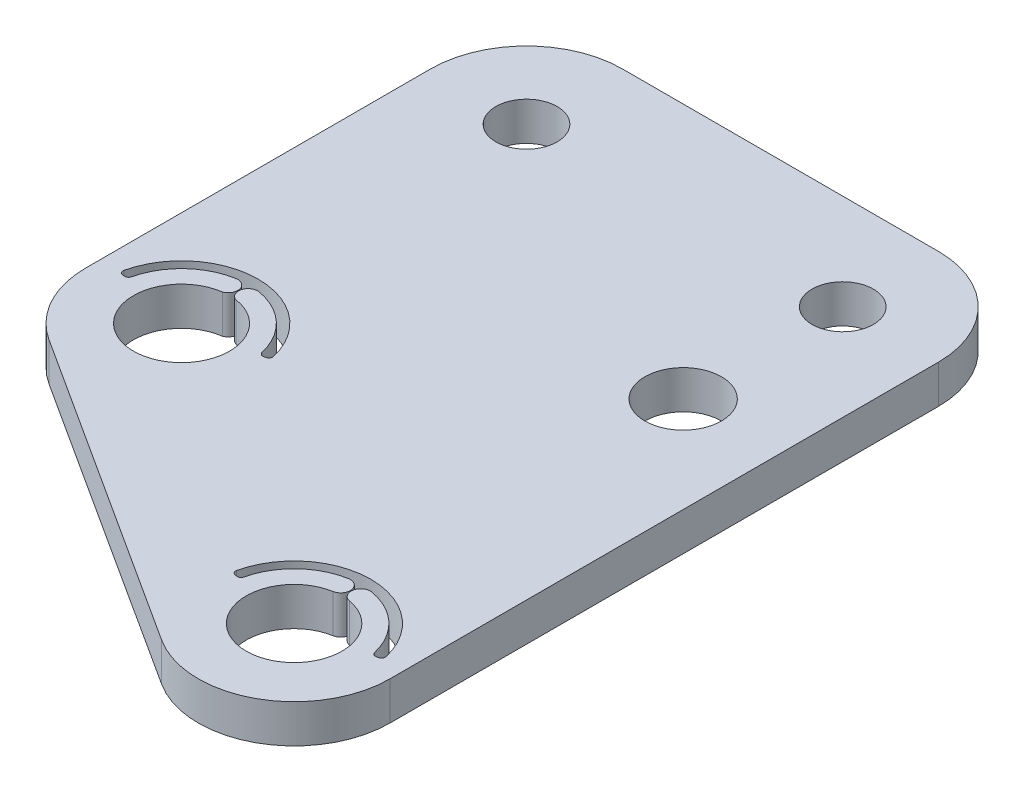
from build123d import *

# Parameters (mm, degrees)
SKETCH1_R           = 2.51
SKETCH1_R_2         = 2.5
SKETCH1_R_3         = 1.6
SKETCH1_R_4         = 2
BOSS_EXTRUDE1_DEPTH = 2
FILLET1_R           = 5
CUT_EXTRUDE2_DEPTH  = 3
SKETCH3_W           = 0.508814103
SKETCH3_H           = 0.135683761
CUT_EXTRUDE3_DEPTH  = 0.4


with BuildPart() as part:
    # Sketch1 → Boss-Extrude1 (new body)
    with BuildSketch(Plane(origin=(0, 0, 0), x_dir=(1, 0, 0), z_dir=(0, 1, 0))):
        Polygon((0, 0), (26.5, 0), (26.5, -42.791666667), (0, -25.727272727), align=None)
        with Locations((5, -23)):
            Circle(SKETCH1_R, mode=Mode.SUBTRACT)
        with Locations((21.5, -33.625)):
            Circle(SKETCH1_R_2, mode=Mode.SUBTRACT)
        with Locations((21.5, -5)):
            Circle(SKETCH1_R_3, mode=Mode.SUBTRACT)
        with Locations((5, -5)):
            Circle(SKETCH1_R_3, mode=Mode.SUBTRACT)
        with Locations((21.5, -13.325)):
            Circle(SKETCH1_R_4, mode=Mode.SUBTRACT)
    extrude(amount=BOSS_EXTRUDE1_DEPTH)

    # Fillet1
    fillet1_edges = [part.edges().sort_by_distance(p)[0] for p in [
        (0, 1, 0),
        (26.5, 1, 0),
        (26.5, 1, 42.791666667),
        (0, 1, 25.727272727),
    ]]
    fillet(fillet1_edges, radius=FILLET1_R)

    # Sketch2 → Cut-Extrude2 (cut, through all)
    with BuildSketch(Plane(origin=(0, 2, 0), x_dir=(1, 0, 0), z_dir=(0, 1, 0))):
        with BuildLine():
            Line((17.861538493, -32.983441068), (17.762917332, -32.966051496))
            ThreePointArc((17.762917332, -32.966051496), (17.630853466, -32.879452656), (17.602786281, -32.724042048))
            ThreePointArc((17.602786281, -32.724042048), (21.5, -29.625), (25.397213719, -32.724042048))
            ThreePointArc((25.397213719, -32.724042048), (25.369146534, -32.879452656), (25.237082668, -32.966051496))
            Line((25.237082668, -32.966051496), (25.138461507, -32.983441068))
            ThreePointArc((25.138461507, -32.983441068), (24.993487988, -32.953351583), (24.908935554, -32.831804949))
            ThreePointArc((24.908935554, -32.831804949), (23.907056069, -31.084118051), (22.107768622, -30.178172864))
            ThreePointArc((22.107768622, -30.178172864), (21.528540656, -30.583752652), (21.934120444, -31.162980617))
            ThreePointArc((21.934120444, -31.162980617), (21.5, -31.125), (21.065879556, -31.162980617))
            ThreePointArc((21.065879556, -31.162980617), (21.471459344, -30.583752652), (20.892231378, -30.178172864))
            ThreePointArc((20.892231378, -30.178172864), (19.092943931, -31.084118051), (18.091064446, -32.831804949))
            ThreePointArc((18.091064446, -32.831804949), (18.006512012, -32.953351583), (17.861538493, -32.983441068))
        make_face()
        with BuildLine():
            Line((1.361538493, -22.358441068), (1.262917332, -22.341051496))
            ThreePointArc((1.262917332, -22.341051496), (1.130853466, -22.254452656), (1.102786281, -22.099042048))
            ThreePointArc((1.102786281, -22.099042048), (5, -19), (8.897213719, -22.099042048))
            ThreePointArc((8.897213719, -22.099042048), (8.869146534, -22.254452656), (8.737082668, -22.341051496))
            Line((8.737082668, -22.341051496), (8.638461507, -22.358441068))
            ThreePointArc((8.638461507, -22.358441068), (8.493487988, -22.328351583), (8.408935554, -22.206804949))
            ThreePointArc((8.408935554, -22.206804949), (7.407056069, -20.459118051), (5.607768622, -19.553172864))
            ThreePointArc((5.607768622, -19.553172864), (5.028540656, -19.958752652), (5.434120444, -20.537980617))
            ThreePointArc((5.434120444, -20.537980617), (5, -20.5), (4.565879556, -20.537980617))
            ThreePointArc((4.565879556, -20.537980617), (4.971459344, -19.958752652), (4.392231378, -19.553172864))
            ThreePointArc((4.392231378, -19.553172864), (2.592943931, -20.459118051), (1.591064446, -22.206804949))
            ThreePointArc((1.591064446, -22.206804949), (1.506512012, -22.328351583), (1.361538493, -22.358441068))
        make_face()
    extrude(amount=-CUT_EXTRUDE2_DEPTH, mode=Mode.SUBTRACT)

    # Sketch3 → Cut-Extrude3 (cut)
    with BuildSketch(Plane(origin=(0, 0, 0), x_dir=(-1, 0, 0), z_dir=(0, 0, -1))):
        Polygon((-16.413127671, 0.4), (-16.238487831, 1.722916667), (-16.22152736, 1.722916667), (-15.675347222, 0.637446581), (-15.130492121, 1.722916667), (-15.113266643, 1.722916667), (-14.937566774, 0.4), (-15.056820079, 0.4), (-15.18349359, 1.351906384), (-15.661036826, 0.4), (-15.687802567, 0.4), (-16.167200855, 1.354026442), (-16.293609358, 0.4), align=None)
        with BuildLine():
            Line((-14.666199252, 1.722916667), (-14.401456914, 1.722916667))
            add(Edge.make_bspline(
                [(-14.401456914, 1.722916667), (-14.383789881, 1.722857859), (-14.349867219, 1.722744941), (-14.301269584, 1.722115323), (-14.257111723, 1.72031073), (-14.217416724, 1.718757783), (-14.182185316, 1.715926008), (-14.151309465, 1.713219454), (-14.124931377, 1.709676433), (-14.108963451, 1.70638599), (-14.101733607, 1.704896167)],
                knots=[0, 0, 0, 0, 5.3002e-05, 0.00010177, 0.00014579, 0.000185584, 0.00022093, 0.000251808, 0.000278568, 0.000300708, 0.000300708, 0.000300708, 0.000300708], degree=3))
            add(Edge.make_bspline(
                [(-14.101733607, 1.704896167), (-14.092054913, 1.702504801), (-14.072903997, 1.697773082), (-14.045330609, 1.687771982), (-14.01905585, 1.676198493), (-13.994188863, 1.662605063), (-13.970854203, 1.646890786), (-13.948811271, 1.629326943), (-13.927960039, 1.610009636), (-13.909143768, 1.588451824), (-13.891401924, 1.565835048), (-13.876438366, 1.541378568), (-13.863539369, 1.515804122), (-13.85326956, 1.488851616), (-13.845000207, 1.460782434), (-13.839169456, 1.431342323), (-13.835672727, 1.400665407), (-13.835316729, 1.379741436), (-13.835136218, 1.369131861)],
                knots=[0, 0, 0, 0, 2.9891e-05, 5.9144e-05, 8.7854e-05, 0.000115962, 0.000144039, 0.000172141, 0.000200452, 0.000229172, 0.000257901, 0.000286582, 0.000315025, 0.000343717, 0.000372985, 0.000402713, 0.000433646, 0.000465465, 0.000465465, 0.000465465, 0.000465465], degree=3))
            add(Edge.make_bspline(
                [(-13.835136218, 1.369131861), (-13.835691464, 1.351504902), (-13.836774894, 1.317110139), (-13.846876346, 1.26719427), (-13.863422829, 1.220631642), (-13.886223596, 1.177480883), (-13.915259528, 1.13858311), (-13.950156101, 1.10441767), (-13.990932782, 1.075827584), (-14.028892672, 1.056001672), (-14.062424527, 1.043304353), (-14.090029381, 1.034370372), (-14.120141601, 1.027467784), (-14.152472677, 1.021284043), (-14.187157154, 1.016615397), (-14.224111901, 1.013196), (-14.263363274, 1.011058904), (-14.290327744, 1.010740646), (-14.304199219, 1.010576923)],
                knots=[0, 0, 0, 0, 5.2832e-05, 0.000103089, 0.000152041, 0.000200646, 0.000248931, 0.000297093, 0.000346506, 0.000397828, 0.000425093, 0.000454008, 0.000484797, 0.000517697, 0.000552739, 0.000589736, 0.000629015, 0.000670628, 0.000670628, 0.000670628, 0.000670628], degree=3))
            Line((-14.304199219, 1.010576923), (-13.818175748, 0.4))
            Line((-13.818175748, 0.4), (-13.964989817, 0.4))
            Line((-13.964989817, 0.4), (-14.451013288, 1.010576923))
            Line((-14.451013288, 1.010576923), (-14.547475962, 1.010576923))
            Line((-14.547475962, 1.010576923), (-14.547475962, 0.4))
            Line((-14.547475962, 0.4), (-14.666199252, 0.4))
            Line((-14.666199252, 0.4), (-14.666199252, 1.722916667))
        make_face()
        with BuildLine():
            Line((-14.547475962, 1.587232906), (-14.547475962, 1.146260684))
            Line((-14.547475962, 1.146260684), (-14.305259248, 1.144405632))
            add(Edge.make_bspline(
                [(-14.305259248, 1.144405632), (-14.293950186, 1.144400629), (-14.272030002, 1.144390932), (-14.240317548, 1.145900484), (-14.210790006, 1.14761775), (-14.183560317, 1.150244437), (-14.158616317, 1.153629619), (-14.135970473, 1.15786408), (-14.11558582, 1.162797449), (-14.09181167, 1.170433183), (-14.065263933, 1.182530696), (-14.036412459, 1.200131346), (-14.011843123, 1.222269078), (-13.991085478, 1.24758345), (-13.974405604, 1.275416199), (-13.962645988, 1.305433695), (-13.955183815, 1.336878139), (-13.95430368, 1.358490102), (-13.953859509, 1.369396868)],
                knots=[0, 0, 0, 0, 3.3922e-05, 6.575e-05, 9.5225e-05, 0.000122649, 0.000147797, 0.000170718, 0.000191735, 0.000210676, 0.000245548, 0.000279004, 0.000311663, 0.000344238, 0.000376915, 0.000408558, 0.000440637, 0.00047332, 0.00047332, 0.00047332, 0.00047332], degree=3))
            add(Edge.make_bspline(
                [(-13.953859509, 1.369396868), (-13.954313882, 1.380035603), (-13.955214283, 1.401117693), (-13.962565455, 1.431981683), (-13.974996858, 1.461111155), (-13.991749609, 1.488387612), (-14.012160004, 1.513147221), (-14.036092629, 1.53433171), (-14.062893105, 1.551812907), (-14.08794204, 1.562983759), (-14.110331162, 1.569832632), (-14.129770349, 1.574652268), (-14.151735104, 1.578524434), (-14.176332078, 1.581626885), (-14.203456265, 1.584293486), (-14.233244815, 1.586089546), (-14.265500086, 1.587153119), (-14.287856218, 1.587205691), (-14.299429087, 1.587232906)],
                knots=[0, 0, 0, 0, 3.189e-05, 6.3195e-05, 9.4547e-05, 0.000126544, 0.000158914, 0.000190451, 0.000222058, 0.000254563, 0.000272332, 0.000292257, 0.000314609, 0.000339196, 0.00036662, 0.000396359, 0.000428707, 0.000463424, 0.000463424, 0.000463424, 0.000463424], degree=3))
            Line((-14.299429087, 1.587232906), (-14.547475962, 1.587232906))
        make_face(mode=Mode.SUBTRACT)
        with BuildLine():
            Line((-13.546808226, 1.722916667), (-13.287366036, 1.722916667))
            add(Edge.make_bspline(
                [(-13.287366036, 1.722916667), (-13.269521437, 1.722897051), (-13.235330394, 1.722859467), (-13.186301191, 1.721719965), (-13.141771918, 1.720197971), (-13.101838589, 1.718088148), (-13.066378338, 1.715594794), (-13.035551621, 1.712097744), (-13.009116134, 1.708446382), (-12.993276493, 1.704734124), (-12.986052684, 1.703041116)],
                knots=[0, 0, 0, 0, 5.3532e-05, 0.00010257, 0.00014712, 0.000187192, 0.000222537, 0.000253734, 0.000280269, 0.000302517, 0.000302517, 0.000302517, 0.000302517], degree=3))
            add(Edge.make_bspline(
                [(-12.986052684, 1.703041116), (-12.976908105, 1.700538176), (-12.958834426, 1.695591276), (-12.932791472, 1.685683113), (-12.908013679, 1.673934795), (-12.884416036, 1.660545389), (-12.862288523, 1.644940428), (-12.841301001, 1.627752484), (-12.821638688, 1.608584718), (-12.80341215, 1.587652117), (-12.78667355, 1.565306085), (-12.772261438, 1.54121304), (-12.760193707, 1.51577853), (-12.749843482, 1.489020245), (-12.742394155, 1.460713486), (-12.736782381, 1.431054937), (-12.733220474, 1.400047777), (-12.732879327, 1.378858482), (-12.732705662, 1.368071832)],
                knots=[0, 0, 0, 0, 2.843e-05, 5.619e-05, 8.3455e-05, 0.000110639, 0.000137472, 0.000164584, 0.000191945, 0.000219742, 0.00024778, 0.000275594, 0.000303805, 0.000332154, 0.000361533, 0.000391471, 0.000422667, 0.000455016, 0.000455016, 0.000455016, 0.000455016], degree=3))
            add(Edge.make_bspline(
                [(-12.732705662, 1.368071832), (-12.732864951, 1.357194517), (-12.73317661, 1.335912317), (-12.73691717, 1.304777364), (-12.741955665, 1.275023687), (-12.749703063, 1.246717258), (-12.759850088, 1.220026178), (-12.771753334, 1.194542557), (-12.786110204, 1.170699943), (-12.802606911, 1.148411777), (-12.820958257, 1.127657137), (-12.8410866, 1.108586426), (-12.862910678, 1.091311275), (-12.886361133, 1.075792954), (-12.911666581, 1.062391325), (-12.938443229, 1.05038782), (-12.966923817, 1.040306794), (-12.986632445, 1.035003765), (-12.996652978, 1.032307525)],
                knots=[0, 0, 0, 0, 3.2613e-05, 6.381e-05, 9.396e-05, 0.000123083, 0.000151681, 0.000179538, 0.000207352, 0.00023502, 0.000262618, 0.000290361, 0.000318091, 0.000346021, 0.000374595, 0.000403898, 0.000433989, 0.000465112, 0.000465112, 0.000465112, 0.000465112], degree=3))
            add(Edge.make_bspline(
                [(-12.996652978, 1.032307525), (-13.004940988, 1.03054503), (-13.023104644, 1.026682417), (-13.053018709, 1.022370292), (-13.087847471, 1.018689711), (-13.127543392, 1.015930055), (-13.172070841, 1.013567565), (-13.221453906, 1.011689743), (-13.275789524, 1.010657924), (-13.313689667, 1.010604707), (-13.333477314, 1.010576923)],
                knots=[0, 0, 0, 0, 2.5414e-05, 5.5697e-05, 9.0611e-05, 0.000130469, 0.000175054, 0.00022438, 0.000278717, 0.000338079, 0.000338079, 0.000338079, 0.000338079], degree=3))
            Line((-13.333477314, 1.010576923), (-13.428084936, 1.010576923))
            Line((-13.428084936, 1.010576923), (-13.428084936, 0.4))
            Line((-13.428084936, 0.4), (-13.546808226, 0.4))
            Line((-13.546808226, 0.4), (-13.546808226, 1.722916667))
        make_face()
        with BuildLine():
            Line((-13.428084936, 1.587232906), (-13.428084936, 1.146260684))
            Line((-13.428084936, 1.146260684), (-13.196468516, 1.143345603))
            add(Edge.make_bspline(
                [(-13.196468516, 1.143345603), (-13.185159497, 1.143339758), (-13.163327668, 1.143328475), (-13.131790762, 1.144834794), (-13.102531894, 1.146573686), (-13.075640939, 1.149119705), (-13.051105773, 1.152718513), (-13.028885487, 1.156351521), (-13.009152377, 1.161607417), (-12.986058333, 1.168684292), (-12.960324449, 1.18075406), (-12.932328679, 1.198273215), (-12.908602892, 1.220604316), (-12.888071869, 1.245712455), (-12.871778874, 1.273644566), (-12.85985146, 1.303530742), (-12.852843344, 1.335064482), (-12.851903622, 1.35664244), (-12.851428953, 1.367541817)],
                knots=[0, 0, 0, 0, 3.3922e-05, 6.5486e-05, 9.4695e-05, 0.000121856, 0.000146479, 0.000169091, 0.000189338, 0.000207693, 0.00024149, 0.000274275, 0.000306345, 0.000338752, 0.000371295, 0.000402938, 0.000434959, 0.000467642, 0.000467642, 0.000467642, 0.000467642], degree=3))
            add(Edge.make_bspline(
                [(-12.851428953, 1.367541817), (-12.851906203, 1.378177505), (-12.852854918, 1.399319937), (-12.85990639, 1.430305956), (-12.871755684, 1.45987719), (-12.888181242, 1.487459279), (-12.908116134, 1.512477071), (-12.931285826, 1.534209616), (-12.957635779, 1.551680319), (-12.982146866, 1.562956589), (-13.003918743, 1.569841529), (-13.022829633, 1.574658776), (-13.044181762, 1.578504912), (-13.067982084, 1.581619248), (-13.094046125, 1.584285289), (-13.12259781, 1.586094274), (-13.153528978, 1.587153158), (-13.175002022, 1.58720568), (-13.18613323, 1.587232906)],
                knots=[0, 0, 0, 0, 3.189e-05, 6.3394e-05, 9.479e-05, 0.000127105, 0.000159345, 0.000190472, 0.000222004, 0.000253783, 0.000271048, 0.000290458, 0.000312289, 0.000336088, 0.000362457, 0.000390874, 0.000421898, 0.00045529, 0.00045529, 0.00045529, 0.00045529], degree=3))
            Line((-13.18613323, 1.587232906), (-13.428084936, 1.587232906))
        make_face(mode=Mode.SUBTRACT)
        with Locations((-12.325654381, 0.908814103)):
            Rectangle(SKETCH3_W, SKETCH3_H)
        with BuildLine():
            add(Edge.make_bspline(
                [(-11.969484509, 1.060928319), (-11.969360525, 1.082131796), (-11.969119687, 1.123319855), (-11.966440432, 1.183336669), (-11.961989633, 1.239640112), (-11.955890091, 1.292232878), (-11.948467402, 1.341128545), (-11.938558572, 1.386196444), (-11.927290042, 1.427645164), (-11.91423004, 1.465609867), (-11.899493584, 1.500602035), (-11.883454444, 1.533268703), (-11.865476084, 1.563560445), (-11.846586001, 1.591960741), (-11.826019534, 1.618004697), (-11.804361955, 1.642060108), (-11.780767972, 1.663571017), (-11.756039633, 1.683167685), (-11.729953052, 1.700346503), (-11.703251807, 1.715477925), (-11.675752109, 1.728404661), (-11.647378879, 1.738568605), (-11.618387138, 1.746963776), (-11.588675539, 1.752704837), (-11.558195023, 1.756317121), (-11.537621237, 1.756662465), (-11.52718725, 1.756837607)],
                knots=[0, 0, 0, 0, 6.3607e-05, 0.000123557, 0.000180183, 0.000233007, 0.000282371, 0.000328477, 0.000371359, 0.000411168, 0.000448819, 0.000485204, 0.000520246, 0.000554424, 0.000587452, 0.000619718, 0.000651413, 0.000683117, 0.000714281, 0.000745015, 0.000775129, 0.00080531, 0.000835341, 0.000865589, 0.000895996, 0.000927285, 0.000927285, 0.000927285, 0.000927285], degree=3))
            add(Edge.make_bspline(
                [(-11.52718725, 1.756837607), (-11.516666101, 1.756653224), (-11.495742848, 1.756286545), (-11.464809135, 1.752762317), (-11.434590059, 1.746914601), (-11.405214453, 1.738628995), (-11.37644102, 1.728349676), (-11.348494819, 1.715465558), (-11.321202261, 1.700467891), (-11.294997063, 1.682845175), (-11.269591539, 1.663197112), (-11.245609719, 1.640986223), (-11.223049422, 1.616436775), (-11.201627506, 1.589811428), (-11.18195173, 1.560599506), (-11.163214153, 1.529309083), (-11.14644258, 1.495392953), (-11.13028989, 1.459417002), (-11.116347487, 1.420385798), (-11.103773638, 1.378519356), (-11.093614028, 1.33332316), (-11.085151416, 1.285034341), (-11.078595459, 1.23347556), (-11.073820621, 1.17875734), (-11.071298354, 1.12084368), (-11.07082335, 1.081247708), (-11.070579594, 1.060928319)],
                knots=[0, 0, 0, 0, 3.1554e-05, 6.275e-05, 9.3258e-05, 0.0001238, 0.00015423, 0.000184825, 0.000216022, 0.000247553, 0.000279465, 0.000312285, 0.000345478, 0.000379416, 0.000414698, 0.000451057, 0.000488745, 0.000528137, 0.000569299, 0.000612983, 0.000659205, 0.000708176, 0.000760013, 0.000815076, 0.000872908, 0.000933869, 0.000933869, 0.000933869, 0.000933869], degree=3))
            add(Edge.make_bspline(
                [(-11.070579594, 1.060928319), (-11.070825877, 1.040697556), (-11.071305751, 1.001278739), (-11.073792345, 0.943625663), (-11.078690399, 0.889197831), (-11.084817389, 0.837864709), (-11.093303318, 0.789839955), (-11.103737414, 0.74495738), (-11.115322506, 0.703023163), (-11.129623158, 0.664380838), (-11.14527542, 0.628491348), (-11.162305211, 0.594977277), (-11.180550056, 0.563542398), (-11.20042735, 0.534438327), (-11.221614206, 0.507458894), (-11.244564084, 0.483080329), (-11.268630049, 0.460715224), (-11.294110337, 0.440814162), (-11.320724227, 0.423395203), (-11.347923045, 0.407817349), (-11.376189383, 0.395256181), (-11.404882672, 0.384470615), (-11.434413334, 0.376230564), (-11.464744559, 0.370533005), (-11.495722065, 0.366537098), (-11.516662538, 0.366232268), (-11.52718725, 0.36607906)],
                knots=[0, 0, 0, 0, 6.0696e-05, 0.000118264, 0.000173063, 0.000224603, 0.000273314, 0.000319277, 0.000362813, 0.000403726, 0.000442769, 0.000480221, 0.000516445, 0.000551727, 0.000585872, 0.000619246, 0.000652065, 0.000684349, 0.000716102, 0.000747428, 0.000778264, 0.000808785, 0.000839326, 0.000870095, 0.000901322, 0.000932875, 0.000932875, 0.000932875, 0.000932875], degree=3))
            add(Edge.make_bspline(
                [(-11.52718725, 0.36607906), (-11.537620947, 0.366255331), (-11.558194163, 0.366602904), (-11.58867886, 0.370198868), (-11.618267759, 0.375980204), (-11.647106872, 0.38407517), (-11.675344156, 0.393983754), (-11.702594835, 0.406893033), (-11.729161906, 0.421760375), (-11.754974489, 0.438691978), (-11.779547538, 0.458090352), (-11.803019332, 0.479545901), (-11.824800217, 0.503594036), (-11.845072628, 0.529855037), (-11.86433962, 0.558087304), (-11.882062687, 0.588676302), (-11.898455837, 0.621500741), (-11.913440132, 0.65677269), (-11.92672549, 0.695006844), (-11.938460785, 0.736640611), (-11.947726553, 0.782041461), (-11.95565761, 0.830844752), (-11.962054624, 0.883260196), (-11.966421884, 0.939316249), (-11.969121131, 0.99897798), (-11.969361172, 1.039901376), (-11.969484509, 1.060928319)],
                knots=[0, 0, 0, 0, 3.1289e-05, 6.1695e-05, 9.1943e-05, 0.000121648, 0.000151489, 0.000181603, 0.000211977, 0.000242773, 0.000274105, 0.000305801, 0.000338066, 0.000371303, 0.000405261, 0.000440532, 0.000477272, 0.000515271, 0.000555417, 0.000598626, 0.000644935, 0.000694341, 0.000746933, 0.000803295, 0.00086298, 0.000926057, 0.000926057, 0.000926057, 0.000926057], degree=3))
        make_face()
        with BuildLine():
            add(Edge.make_bspline(
                [(-11.850761218, 1.061458333), (-11.85071607, 1.043788438), (-11.850628446, 1.009494642), (-11.848339346, 0.959661028), (-11.845220955, 0.913181172), (-11.841198798, 0.869996055), (-11.83522566, 0.830251854), (-11.828532916, 0.793675218), (-11.820388251, 0.760459715), (-11.810751741, 0.730377417), (-11.799775654, 0.702917799), (-11.787791592, 0.677366149), (-11.77491745, 0.653420626), (-11.760509319, 0.631296315), (-11.744817613, 0.610921069), (-11.728196768, 0.591934254), (-11.710026476, 0.575002062), (-11.684889645, 0.55469459), (-11.651704668, 0.533709679), (-11.60989277, 0.515436008), (-11.566928802, 0.503952163), (-11.537767466, 0.502491755), (-11.523212139, 0.501762821)],
                knots=[0, 0, 0, 0, 5.3004e-05, 0.000102871, 0.00014962, 0.00019276, 0.000232937, 0.000270151, 0.00030428, 0.000335457, 0.000364836, 0.000392933, 0.000420089, 0.00044633, 0.000472037, 0.000497192, 0.000521939, 0.00054644, 0.000594082, 0.00063918, 0.000682952, 0.000726571, 0.000726571, 0.000726571, 0.000726571], degree=3))
            add(Edge.make_bspline(
                [(-11.523212139, 0.501762821), (-11.508562662, 0.502366744), (-11.479293954, 0.503573343), (-11.436532073, 0.515214532), (-11.395018846, 0.532778912), (-11.362485702, 0.553547761), (-11.337734859, 0.573326623), (-11.320001354, 0.590189898), (-11.303724925, 0.609072026), (-11.288287593, 0.629444677), (-11.274128955, 0.651697074), (-11.2612539, 0.675722214), (-11.249505134, 0.701586814), (-11.242811537, 0.719642638), (-11.239389273, 0.728874115)],
                knots=[0, 0, 0, 0, 4.3862e-05, 8.7633e-05, 0.000132034, 0.000178721, 0.00020285, 0.00022703, 0.000252009, 0.000277556, 0.000303654, 0.000331043, 0.00035927, 0.000388799, 0.000388799, 0.000388799, 0.000388799], degree=3))
            add(Edge.make_bspline(
                [(-11.239389273, 0.728874115), (-11.235400956, 0.740678213), (-11.227302962, 0.764645594), (-11.216866369, 0.801824713), (-11.208647126, 0.8408329), (-11.201252639, 0.881437037), (-11.196205502, 0.923936567), (-11.192143084, 0.968199991), (-11.189750235, 1.014260685), (-11.189453618, 1.04555522), (-11.189302885, 1.061458333)],
                knots=[0, 0, 0, 0, 3.7376e-05, 7.589e-05, 0.000115758, 0.000156931, 0.000199662, 0.000244097, 0.00029027, 0.000337978, 0.000337978, 0.000337978, 0.000337978], degree=3))
            add(Edge.make_bspline(
                [(-11.189302885, 1.061458333), (-11.189510843, 1.077358874), (-11.189917654, 1.108463731), (-11.191472644, 1.154016734), (-11.195488102, 1.197282822), (-11.199947888, 1.238448388), (-11.206523623, 1.277285556), (-11.213613628, 1.314119451), (-11.223139086, 1.348493749), (-11.23331412, 1.380946626), (-11.244959716, 1.411109374), (-11.257779056, 1.43912262), (-11.271470018, 1.465121609), (-11.286340448, 1.489035006), (-11.302213817, 1.510969926), (-11.319509081, 1.530486573), (-11.337540198, 1.548189832), (-11.362795503, 1.56839741), (-11.395858702, 1.589001533), (-11.436999765, 1.607962996), (-11.479813372, 1.618851845), (-11.508756314, 1.620387066), (-11.523212139, 1.621153846)],
                knots=[0, 0, 0, 0, 4.7708e-05, 9.3327e-05, 0.000136682, 0.000178034, 0.000217506, 0.000254822, 0.0002905, 0.000324443, 0.000356826, 0.000387421, 0.000416822, 0.000444912, 0.000471839, 0.00049794, 0.000523053, 0.000547555, 0.000594832, 0.000639552, 0.000683001, 0.000726356, 0.000726356, 0.000726356, 0.000726356], degree=3))
            add(Edge.make_bspline(
                [(-11.523212139, 1.621153846), (-11.537843822, 1.620386008), (-11.567133841, 1.618848932), (-11.610392443, 1.608003565), (-11.651858076, 1.589099855), (-11.684833843, 1.568329167), (-11.710106763, 1.548546531), (-11.7279029, 1.531391532), (-11.744589102, 1.51262643), (-11.759960524, 1.492063801), (-11.774357366, 1.469965284), (-11.787579356, 1.446157031), (-11.799492156, 1.420518391), (-11.810485418, 1.393071107), (-11.820151323, 1.362991405), (-11.828124339, 1.329816815), (-11.835489981, 1.293356516), (-11.840704265, 1.25339706), (-11.845339672, 1.210201127), (-11.848318634, 1.163605235), (-11.850636104, 1.113688044), (-11.850718678, 1.079216934), (-11.850761218, 1.061458333)],
                knots=[0, 0, 0, 0, 4.3883e-05, 8.7847e-05, 0.000132809, 0.000180086, 0.000204422, 0.000228976, 0.000254131, 0.000279678, 0.000305919, 0.000333203, 0.0003613, 0.000390679, 0.000421855, 0.000455985, 0.000492989, 0.00053339, 0.000576821, 0.000623306, 0.000673437, 0.000726706, 0.000726706, 0.000726706, 0.000726706], degree=3))
        make_face(mode=Mode.SUBTRACT)
        Polygon((-10.67068351, 1.722916667), (-10.426081731, 1.722916667), (-10.426081731, 0.4), (-10.544805021, 0.4), (-10.544805021, 1.587232906), (-10.748330662, 1.587232906), align=None)
    extrude(amount=-CUT_EXTRUDE3_DEPTH, mode=Mode.SUBTRACT)


solid = part.part
